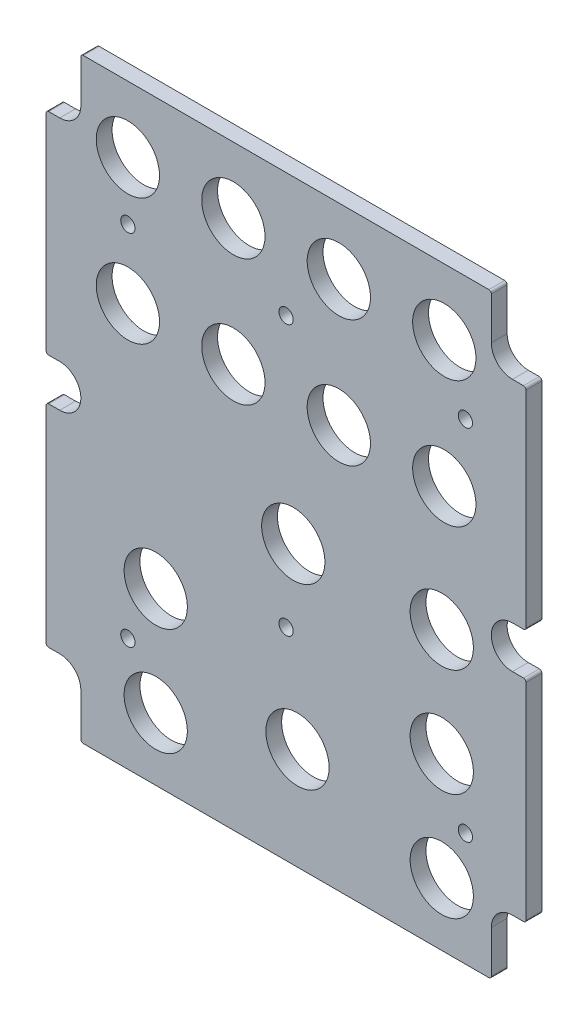
from build123d import *

# Parameters (mm, degrees)
BOSS_EXTRUDE1_DEPTH         = 4.7625
F_3_4_0_75_DIAMETER_HOLE1_D = 19.05
F_6_CLEARANCE_HOLE1_D       = 4.3053


with BuildPart() as part:
    # Sketch1 → Boss-Extrude1 (new body)
    with BuildSketch(Plane.XY.offset(-4.2926)):
        with BuildLine():
            Line((11.2395, 14.2875), (11.2395, 1.55575))
            ThreePointArc((11.2395, 1.55575), (11.462684633, 1.016934633), (12.0015, 0.79375))
            Line((12.0015, 0.79375), (134.0485, 0.79375))
            ThreePointArc((134.0485, 0.79375), (134.587315367, 1.016934633), (134.8105, 1.55575))
            Line((134.8105, 1.55575), (134.8105, 14.2875))
            ThreePointArc((134.8105, 14.2875), (136.670371939, 18.777628061), (141.1605, 20.6375))
            Line((141.1605, 20.6375), (144.494250007, 20.6375))
            ThreePointArc((144.494250007, 20.6375), (145.033065373, 20.860684631), (145.256250007, 21.399499996))
            Line((145.256250007, 21.399499996), (145.256250453, 83.375499964))
            ThreePointArc((145.256250453, 83.375499964), (145.033065866, 83.914315228), (144.494250605, 84.137499968))
            Line((144.494250605, 84.137499968), (141.16049997, 84.137499992))
            ThreePointArc((141.16049997, 84.137499992), (134.8105, 90.487500015), (141.1605, 96.8375))
            Line((141.1605, 96.8375), (144.49425, 96.8375))
            ThreePointArc((144.49425, 96.8375), (145.033065367, 97.060684633), (145.25625, 97.5995))
            Line((145.25625, 97.5995), (145.25625, 159.5755))
            ThreePointArc((145.25625, 159.5755), (145.033065367, 160.114315367), (144.49425, 160.3375))
            Line((144.49425, 160.3375), (141.1605, 160.3375))
            ThreePointArc((141.1605, 160.3375), (136.670371939, 162.197371939), (134.8105, 166.6875))
            Line((134.8105, 166.6875), (134.8105, 179.41925))
            ThreePointArc((134.8105, 179.41925), (134.587315367, 179.958065367), (134.0485, 180.18125))
            Line((134.0485, 180.18125), (12.0015, 180.18125))
            ThreePointArc((12.0015, 180.18125), (11.462684633, 179.958065367), (11.2395, 179.41925))
            Line((11.2395, 179.41925), (11.2395, 166.6875))
            ThreePointArc((11.2395, 166.6875), (9.379628061, 162.197371939), (4.8895, 160.3375))
            Line((4.8895, 160.3375), (1.55575, 160.3375))
            ThreePointArc((1.55575, 160.3375), (1.016934633, 160.114315367), (0.79375, 159.5755))
            Line((0.79375, 159.5755), (0.79375, 97.5995))
            ThreePointArc((0.79375, 97.5995), (1.016934633, 97.060684633), (1.55575, 96.8375))
            Line((1.55575, 96.8375), (4.8895, 96.8375))
            ThreePointArc((4.8895, 96.8375), (11.2395, 90.487500015), (4.88950003, 84.1375))
            Line((4.88950003, 84.1375), (1.555749996, 84.137499976))
            ThreePointArc((1.555749996, 84.137499976), (1.016934626, 83.91431534), (0.79375, 83.375499968))
            Line((0.79375, 83.375499968), (0.79375, 21.3995))
            ThreePointArc((0.79375, 21.3995), (1.016934633, 20.860684633), (1.55575, 20.6375))
            Line((1.55575, 20.6375), (4.8895, 20.6375))
            ThreePointArc((4.8895, 20.6375), (9.379628061, 18.777628061), (11.2395, 14.2875))
        make_face()
    extrude(amount=BOSS_EXTRUDE1_DEPTH)

    # 3/4 (0.75) Diameter Hole1 (through all)
    with Locations(Plane.XY.offset(0.4699)):
        with Locations((33.782, 19.685), (76.454, 31.496), (119.888, 19.685), (119.888, 52.07), (33.782, 52.07), (75.184, 84.455), (119.888, 84.455), (25.4, 122.2248), (57.15, 122.2248), (88.9, 122.2248), (120.65, 122.2248), (25.4, 160.3248), (57.15, 160.3248), (88.9, 160.3248), (120.65, 160.3248)):
            Hole(F_3_4_0_75_DIAMETER_HOLE1_D / 2)

    # #6 Clearance Hole1 (through all)
    with Locations(Plane.XY.offset(0.4699)):
        with Locations((25.4, 142.875), (73.025, 142.875), (127, 142.875), (73.025, 61.647038728), (25.4, 34.925), (127, 34.925)):
            Hole(F_6_CLEARANCE_HOLE1_D / 2)


solid = part.part
